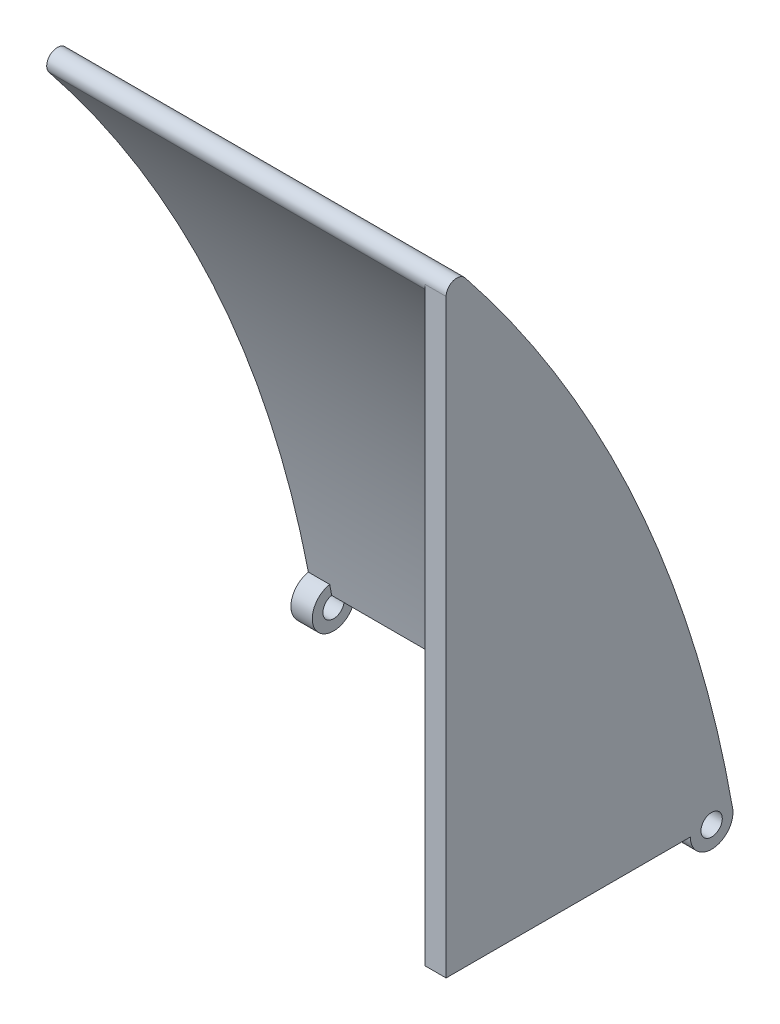
from build123d import *

# Parameters (mm, degrees)
BOSS_EXTRUDE8_DEPTH  = 46.84
SKETCH10_R           = 5
BOSS_EXTRUDE9_DEPTH  = 5
SKETCH11_R           = 2.5
CUT_EXTRUDE4_DEPTH   = 94.68
BOSS_EXTRUDE10_DEPTH = 5


with BuildPart() as part:
    # Sketch9 → Boss-Extrude8 (new body, symmetric)
    with BuildSketch(Plane(origin=(0, 0, 0), x_dir=(0, 0, -1), z_dir=(1, 0, 0))):
        with BuildLine():
            Line((0, 0), (-0.173648178, 0.984807753))
            ThreePointArc((-0.173648178, 0.984807753), (-22.828245747, 74.423796966), (-62.906637971, 140))
            ThreePointArc((-62.906637971, 140), (-66.419974037, 140.395562491), (-66.815536529, 136.882226425))
            ThreePointArc((-66.815536529, 136.882226425), (-27.385689632, 72.367172247), (-5.097686943, 0.116566865))
            Line((-5.097686943, 0.116566865), (-5.077133059, 0))
            Line((-5.077133059, 0), (0, 0))
        make_face()
    extrude(amount=BOSS_EXTRUDE8_DEPTH, both=True)

    # Sketch10 → Boss-Extrude9 (add)
    with BuildSketch(Plane(origin=(46.84, 0, 0), x_dir=(0, 0, -1), z_dir=(1, 0, 0))):
        with Locations((-5.077133059, 0)):
            Circle(SKETCH10_R)
    boss_extrude9 = extrude(amount=-BOSS_EXTRUDE9_DEPTH)

    # Mirror1: Boss-Extrude9 across plane
    add(boss_extrude9.mirror(Plane(origin=(0, 0, 0), x_dir=(0, 0, 1), z_dir=(1, 0, 0))))

    # Sketch11 → Cut-Extrude4 (cut, through all)
    with BuildSketch(Plane(origin=(46.84, 0, 0), x_dir=(0, 0, -1), z_dir=(1, 0, 0))):
        with Locations((-5.077133059, 0)):
            Circle(SKETCH11_R)
    extrude(amount=-CUT_EXTRUDE4_DEPTH, mode=Mode.SUBTRACT)

    # Sketch13 → Boss-Extrude10 (add)
    with BuildSketch(Plane(origin=(46.84, 0, 0), x_dir=(0, 0, -1), z_dir=(1, 0, 0))):
        with BuildLine():
            Line((-10.077133059, 0), (-67.36108725, 0))
            Line((-67.36108725, 0), (-67.36108725, 138.441113213))
            ThreePointArc((-67.36108725, 138.441113213), (-67.220761295, 137.615317595), (-66.815536529, 136.882226425))
            ThreePointArc((-66.815536529, 136.882226425), (-28.39859142, 74.587920976), (-5.983948215, 4.917081072))
            ThreePointArc((-5.983948215, 4.917081072), (-8.919923438, 3.198900141), (-10.077133059, 0))
        make_face()
    extrude(amount=-BOSS_EXTRUDE10_DEPTH)


solid = part.part
